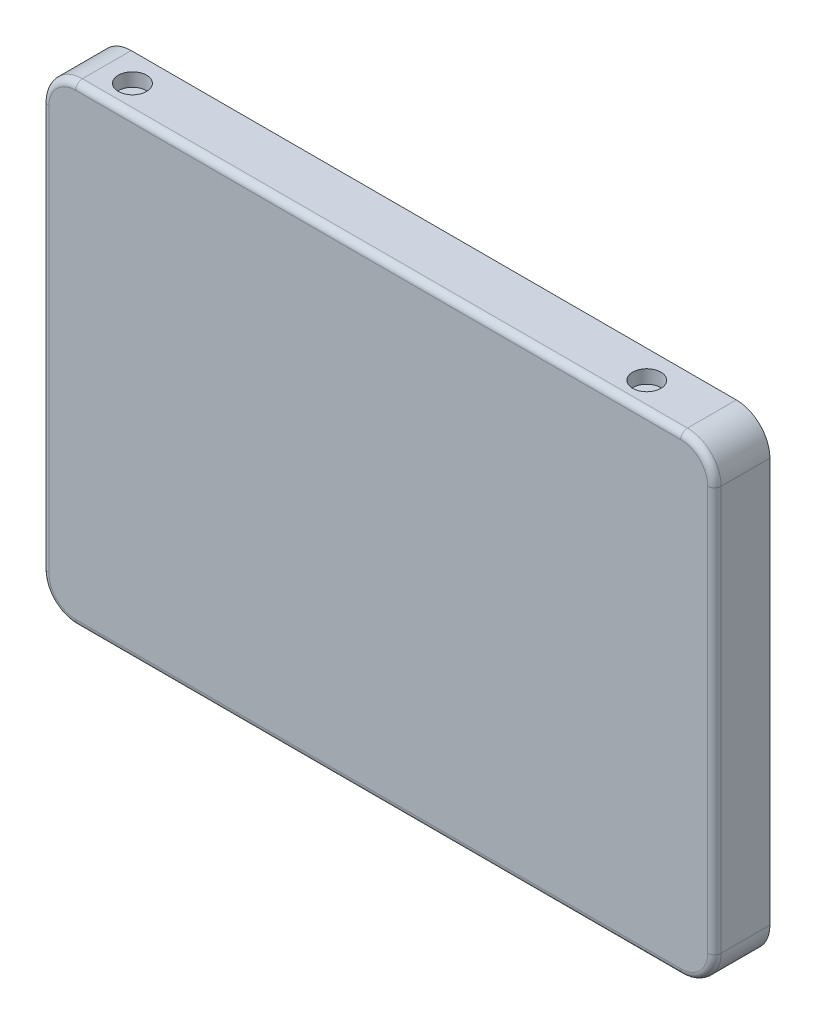
from build123d import *

# Parameters (mm, degrees)
SKETCH2_W           = 100
SKETCH2_H           = 70.15
BOSS_EXTRUDE1_DEPTH = 8.25
FILLET1_R           = 5
CUT_EXTRUDE1_START  = -35.075
SKETCH3_R           = 2.1
CUT_EXTRUDE1_DEPTH  = 2
FILLET2_R           = 1
SKETCH4_R           = 2
CUT_EXTRUDE2_DEPTH  = 2


with BuildPart() as part:
    # Sketch2 → Boss-Extrude1 (new body)
    with BuildSketch(Plane.XY):
        with Locations((50, 0)):
            Rectangle(SKETCH2_W, SKETCH2_H)
    extrude(amount=BOSS_EXTRUDE1_DEPTH)

    # Fillet1
    fillet1_edges = [part.edges().sort_by_distance(p)[0] for p in [
        (0, 35.075, 4.125),
        (100, 35.075, 4.125),
        (100, -35.075, 4.125),
        (0, -35.075, 4.125),
    ]]
    fillet(fillet1_edges, radius=FILLET1_R)

    # Sketch3 → Cut-Extrude1 (cut)
    with BuildSketch(Plane(origin=(0, 0, 0), x_dir=(1, 0, 0), z_dir=(0, 1, 0)).offset(CUT_EXTRUDE1_START)):
        with Locations((9.31, -4.125)):
            Circle(SKETCH3_R)
        with Locations((85.81, -4.125)):
            Circle(SKETCH3_R)
    cut_extrude1 = extrude(amount=CUT_EXTRUDE1_DEPTH, mode=Mode.SUBTRACT)

    # Mirror1: Cut-Extrude1 across plane
    add(cut_extrude1.mirror(Plane.ZX), mode=Mode.SUBTRACT)

    # Fillet2
    fillet2_edges = [part.edges().sort_by_distance(p)[0] for p in [
        (100, 0, 8.25),
        (50, -35.075, 8.25),
        (0, 0, 8.25),
        (50, 35.075, 8.25),
        (1.464466094, 33.610533906, 8.25),
        (98.535533906, 33.610533906, 8.25),
        (1.464466094, -33.610533906, 8.25),
        (98.535533906, -33.610533906, 8.25),
    ]]
    fillet(fillet2_edges, radius=FILLET2_R)

    # Sketch4 → Cut-Extrude2 (cut)
    with BuildSketch(Plane.XY):
        with Locations((9.31, -30.925)):
            Circle(SKETCH4_R)
        with Locations((9.31, 30.925)):
            Circle(SKETCH4_R)
    cut_extrude2 = extrude(amount=CUT_EXTRUDE2_DEPTH, mode=Mode.SUBTRACT)

    # Mirror2: Cut-Extrude2 across plane
    add(cut_extrude2.mirror(Plane(origin=(47.56, 0, 0), x_dir=(0, 0, 1), z_dir=(1, 0, 0))), mode=Mode.SUBTRACT)


solid = part.part
